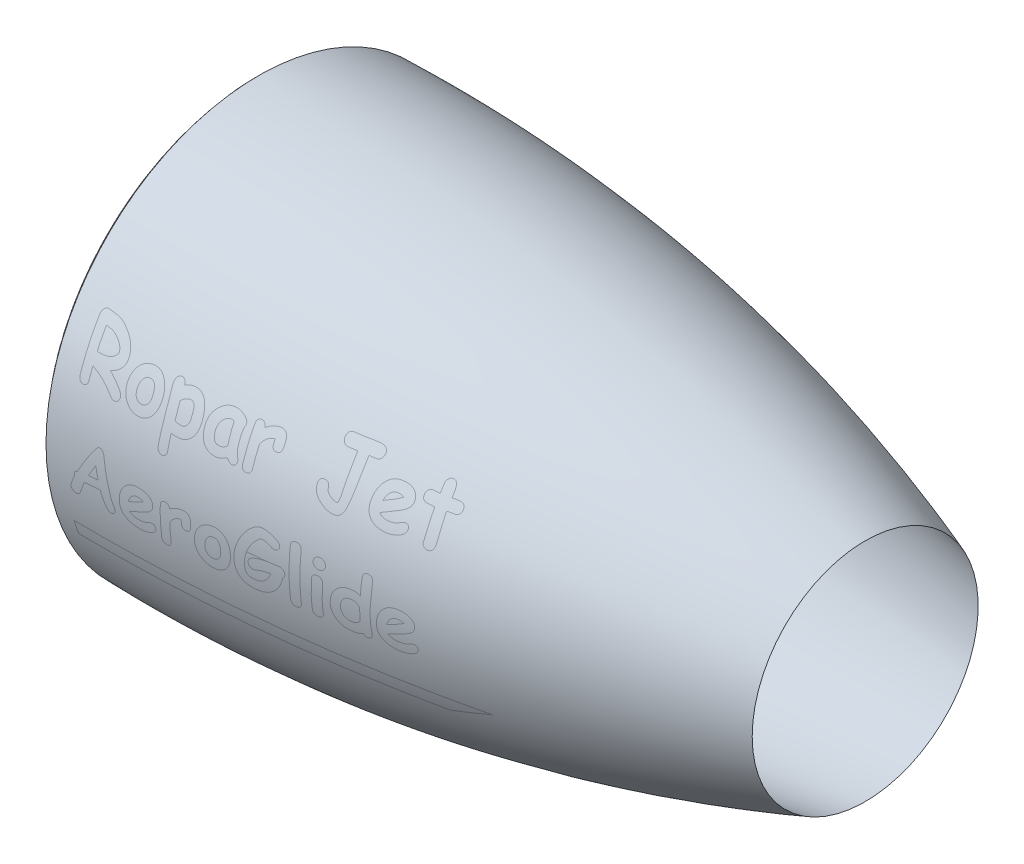
from build123d import *


with BuildPart() as part:
    # Sketch1 → Revolve1 (revolve)
    with BuildSketch(Plane.XY):
        with BuildLine():
            Line((0, 180), (25, 180))
            Line((25, 180), (32.862281051, 190))
            Line((32.862281051, 190), (57.862281051, 190))
            Line((57.862281051, 190), (580, 108))
            add(Edge.make_bspline(
                [(0, 203.022852395), (299.257043437, 210.150543868), (580, 108)],
                knots=[0, 0, 0, 1, 1, 1], degree=2))
            add(Edge.make_bspline(
                [(0, 203.022852395), (-11.74223398, 191.655576066), (0, 180)],
                knots=[0, 0, 0, 1, 1, 1], degree=2))
        make_face()
    revolve(axis=Axis((0, 0, 0), (1, 0, 0)))


solid = part.part
